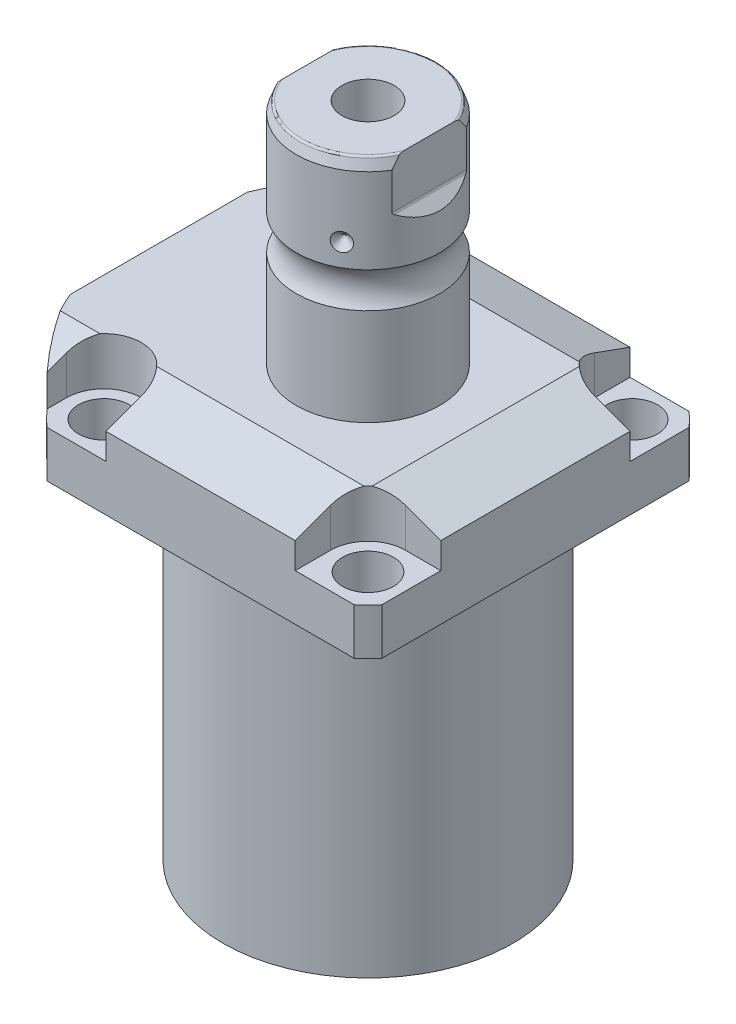
from build123d import *

# Parameters (mm, degrees)
SKETCH1_W               = 88.9
SKETCH1_H               = 100
EXTRUDE1_DEPTH          = 113.919
SKETCH2_OUTSIDE_W       = 137.146
SKETCH2_OUTSIDE_H       = 126.046
SKETCH2_OUTSIDE_R       = 60.325
CUT_EXTRUDE1_DEPTH      = 114.919
SKETCH3_W               = 38.1002
SKETCH3_H               = 88.9
FILLET1_R               = 0.381
CUT_EXTRUDE2_DEPTH      = 12.7
CUT_EXTRUDE9_START      = -56.55
CUT_EXTRUDE9_DEPTH      = 102
CUT_EXTRUDE7_DEPTH      = 45.45
CUT_EXTRUDE7_DEPTH_BACK = 45.45
SKETCH10_R              = 1.1811
SKETCH11_R              = 1.1811
LPATTERN1_COUNT         = 2
LPATTERN1_PITCH         = 25.9588
CUT_EXTRUDE8_DEPTH      = 53.34
SKETCH17_W              = 6.7435
SKETCH17_H              = 12.319
HOLE1_AT_2_COUNT        = 2
HOLE1_AT_2_PITCH        = 70.104
HOLE1_AT_3_COUNT        = 2
HOLE1_AT_3_PITCH        = 99.142027577
HOLE1_AT_4_COUNT        = 2
HOLE1_AT_4_PITCH        = 70.104
CHAMFER1_SIZE           = 0.635
FILLET2_R               = 0.635
CIRPATTERN1_COUNT       = 3


with BuildPart() as part:
    # Sketch1 → Extrude1 (new body)
    with BuildSketch(Plane.ZX):
        with Locations((0, -5.55)):
            Rectangle(SKETCH1_W, SKETCH1_H)
    extrude(amount=EXTRUDE1_DEPTH)

    # Sketch2 outside → Cut-Extrude1 (cut, through all)
    with BuildSketch(Plane.XZ):
        with Locations((-5.55, 0)):
            Rectangle(SKETCH2_OUTSIDE_W, SKETCH2_OUTSIDE_H)
        Circle(SKETCH2_OUTSIDE_R, mode=Mode.SUBTRACT)
    extrude(amount=-CUT_EXTRUDE1_DEPTH, mode=Mode.SUBTRACT)

    # Sketch3 → Cut-Revolve1 (revolve, cut)
    with BuildSketch(Plane(origin=(0, 0, 0), x_dir=(0, 0, 1), z_dir=(1, 0, 0))):
        with Locations((57.5436, -44.45)):
            Rectangle(SKETCH3_W, SKETCH3_H)
    revolve(axis=Axis((0, 93.345, 0), (0, -1, 0)), mode=Mode.SUBTRACT)

    # Fillet1
    fillet1_edges = [part.edges().sort_by_distance(p)[0] for p in [
        (0, 88.9, -38.4935),
    ]]
    fillet(fillet1_edges, radius=FILLET1_R)

    # Sketch4 → Cut-Extrude2 (cut)
    with BuildSketch(Plane(origin=(0, 113.919, 0), x_dir=(-1, 0, 0), z_dir=(0, 1, 0))):
        with BuildLine():
            Line((-25.121, -44.45), (-25.121, -35.052))
            ThreePointArc((-25.121, -35.052), (-28.029722556, -28.029722556), (-35.052, -25.121))
            Line((-35.052, -25.121), (-44.45, -25.121))
            Line((-44.45, -25.121), (-44.45, -44.45))
            Line((-44.45, -44.45), (-25.121, -44.45))
        make_face()
        with BuildLine():
            Line((44.983, -44.45), (25.121, -44.45))
            Line((25.121, -44.45), (25.121, -35.052))
            ThreePointArc((25.121, -35.052), (35.052, -25.121), (44.983, -35.052))
            Line((44.983, -35.052), (44.983, -44.45))
        make_face()
        with BuildLine():
            Line((25.121, 44.45), (25.121, 35.052))
            ThreePointArc((25.121, 35.052), (35.052, 25.121), (44.983, 35.052))
            Line((44.983, 35.052), (44.983, 44.45))
            Line((44.983, 44.45), (25.121, 44.45))
        make_face()
        with BuildLine():
            Line((-35.052, 25.121), (-44.45, 25.121))
            Line((-44.45, 25.121), (-44.45, 44.45))
            Line((-44.45, 44.45), (-25.121, 44.45))
            Line((-25.121, 44.45), (-25.121, 35.052))
            ThreePointArc((-25.121, 35.052), (-28.029722556, 28.029722556), (-35.052, 25.121))
        make_face()
    extrude(amount=-CUT_EXTRUDE2_DEPTH, mode=Mode.SUBTRACT)

    # Sketch5 → Cut-Extrude9 (cut)
    with BuildSketch(Plane(origin=(0, 0, 0), x_dir=(0, 0, -1), z_dir=(1, 0, 0)).offset(CUT_EXTRUDE9_START)):
        Polygon((-28.575, 113.919), (-44.45, 108.140972531), (-44.45, 113.919), align=None)
    cut_extrude9 = extrude(amount=CUT_EXTRUDE9_DEPTH, mode=Mode.SUBTRACT)

    # Mirror1: Cut-Extrude9 across plane
    add(cut_extrude9.mirror(Plane.XY), mode=Mode.SUBTRACT)

    # Sketch9 → Cut-Extrude7 (cut, two sides)
    with BuildSketch(Plane.XY) as cut_extrude7_sk:
        Polygon((28.575, 113.919), (44.45, 108.140972531), (44.45, 113.919), align=None)
    extrude(amount=CUT_EXTRUDE7_DEPTH, mode=Mode.SUBTRACT)
    extrude(cut_extrude7_sk.sketch, amount=-CUT_EXTRUDE7_DEPTH_BACK, mode=Mode.SUBTRACT)

    # Sketch20 → Cut-Revolve4 (revolve, cut)
    with BuildSketch(Plane(origin=(-41.402, 88.9, -18.1102), x_dir=(0, 1, 0), z_dir=(1, 0, 0)), mode=Mode.PRIVATE) as cut_revolve4_sk:
        Polygon((0, 41.9225), (1.4478, 41.9225), (1.4478, 39.4714), (2.4638, 39.4714), (2.4638, 37.4648), (13.4366, 37.4648), (13.4366, 36.2202), (0, 36.2202), align=None)
    cut_revolve4 = revolve(cut_revolve4_sk.sketch.rotate(Axis((-41.402, 81.620304954, 18.11), (0, 1, 0)), 180), axis=Axis((-41.402, 81.620304954, 18.11), (0, 1, 0)), mode=Mode.SUBTRACT)  # turned: the seam where the file's is

    # Mirror10: Cut-Revolve4 across plane
    add(cut_revolve4.mirror(Plane.XY), mode=Mode.SUBTRACT)

    # S2D0007 → Cut-Revolve2 (revolve, cut)
    with BuildSketch(Plane(origin=(-55.5498, 101.9048, 12.9794), x_dir=(0, 1, 0), z_dir=(0, 0, 1)), mode=Mode.PRIVATE) as cut_revolve2_sk:
        Polygon((0.0002, 0.0002), (10.7444, 0.0002), (10.7444, -0.2538), (6.655, -0.2538), (5.9438, -0.965), (5.9438, -14.427), (0.0002, -14.427), align=None)
    cut_revolve2 = revolve(cut_revolve2_sk.sketch.rotate(Axis((-40.6146, 101.905, 12.9794), (-1, 0, 0)), 90), axis=Axis((-40.6146, 101.905, 12.9794), (-1, 0, 0)), mode=Mode.SUBTRACT)  # turned: the seam where the file's is

    # LPattern1: Cut-Revolve2 ×2
    with Locations(*[(0, 0, -i * LPATTERN1_PITCH) for i in range(1, LPATTERN1_COUNT)]):
        add(cut_revolve2, mode=Mode.SUBTRACT)

    # Sketch15 → Revolve3 (revolve)
    with BuildSketch(Plane(origin=(0, 0, 0), x_dir=(0, -1, 0), z_dir=(1, 0, 0)), mode=Mode.PRIVATE) as revolve3_sk:
        with BuildLine():
            Line((-113.919, 0), (-113.919, 19.05))
            Line((-113.919, 19.05), (-139.640705156, 19.05))
            ThreePointArc((-139.640705156, 19.05), (-144.348, 17.5005), (-149.055294844, 19.05))
            Line((-149.055294844, 19.05), (-171.602, 19.05))
            Line((-171.602, 19.05), (-174.523, 17.986842946))
            Line((-174.523, 17.986842946), (-174.523, 0))
            Line((-174.523, 0), (-113.919, 0))
        make_face()
    revolve(revolve3_sk.sketch.rotate(Axis((0, 197.63613, 0), (0, -1, 0)), 180), axis=Axis((0, 197.63613, 0), (0, -1, 0)))  # turned: the seam where the file's is

    # Sketch16 → Cut-Extrude8 (cut, symmetric)
    with BuildSketch(Plane(origin=(0, 0, 0), x_dir=(0, -1, 0), z_dir=(0, 0, 1))):
        with BuildLine():
            Line((-174.523, 19.05), (-158.738369265, 19.05))
            Line((-158.738369265, 19.05), (-161.284184633, 16.504184633))
            ThreePointArc((-161.284184633, 16.504184633), (-161.531395225, 16.339003796), (-161.823, 16.281))
            Line((-161.823, 16.281), (-174.523, 16.281))
            Line((-174.523, 16.281), (-174.523, 19.05))
        make_face()
        with BuildLine():
            Line((-174.523, -19.05), (-174.523, -16.281))
            Line((-174.523, -16.281), (-161.823, -16.281))
            ThreePointArc((-161.823, -16.281), (-161.531395225, -16.339003796), (-161.284184633, -16.504184633))
            Line((-161.284184633, -16.504184633), (-158.738369265, -19.05))
            Line((-158.738369265, -19.05), (-174.523, -19.05))
        make_face()
    extrude(amount=CUT_EXTRUDE8_DEPTH, both=True, mode=Mode.SUBTRACT)

    # Sketch17 → Hole1 (revolve, cut)
    with BuildSketch(Plane(origin=(35.052, 101.219, -35.052), x_dir=(0, 0, 1), z_dir=(1, 0, 0))):
        with Locations((3.37175, 6.1595)):
            Rectangle(SKETCH17_W, SKETCH17_H)
    hole1 = revolve(axis=Axis((35.052, -8.781, -35.052), (0, 1, 0)), mode=Mode.SUBTRACT)

    # Hole1 at 2: Hole1 ×2
    with Locations(*[(0, 0, i * HOLE1_AT_2_PITCH) for i in range(1, HOLE1_AT_2_COUNT)]):
        add(hole1, mode=Mode.SUBTRACT)

    # Hole1 at 3: Hole1 ×2
    with Locations(*[Vector(-0.707106781, 0, 0.707106781) * (i * HOLE1_AT_3_PITCH) for i in range(1, HOLE1_AT_3_COUNT)]):
        add(hole1, mode=Mode.SUBTRACT)

    # Hole1 at 4: Hole1 ×2
    with Locations(*[(-i * HOLE1_AT_4_PITCH, 0, 0) for i in range(1, HOLE1_AT_4_COUNT)]):
        add(hole1, mode=Mode.SUBTRACT)

    # Chamfer1
    chamfer1_edges = [part.edges().sort_by_distance(p)[0] for p in [
        (-41.402, 91.3638, 19.3546),
        (-41.402, 91.3638, -19.3546),
    ]]
    chamfer(chamfer1_edges, length=CHAMFER1_SIZE)

    # Sketch21 → Cut-Revolve5 (revolve, cut)
    with BuildSketch(Plane.XY, mode=Mode.PRIVATE) as cut_revolve5_sk:
        Polygon((0, 144.956512296), (6.9342, 149.123), (6.9342, 174.523), (0, 174.523), align=None)
    revolve(cut_revolve5_sk.sketch.rotate(Axis((0, 0, 0), (0, 1, 0)), 270), axis=Axis((0, 0, 0), (0, 1, 0)), mode=Mode.SUBTRACT)  # turned: the seam where the file's is

    # Fillet2
    fillet2_edges = [part.edges().sort_by_distance(p)[0] for p in [
        (0, 174.523, -17.986842946),
        (0, 174.523, 17.986842946),
    ]]
    fillet(fillet2_edges, radius=FILLET2_R)

    # Sketch22 → Cut-Revolve6 (revolve, cut)
    with BuildSketch(Plane.XY, mode=Mode.PRIVATE) as cut_revolve6_sk:
        Polygon((-19.05, 157.429), (-16.637, 155.016), (-19.05, 155.016), align=None)
    cut_revolve6 = revolve(cut_revolve6_sk.sketch.rotate(Axis((-37.997376206, 155.016, 0), (1, 0, 0)), 90), axis=Axis((-37.997376206, 155.016, 0), (1, 0, 0)), mode=Mode.SUBTRACT)  # turned: the seam where the file's is

    # CirPattern1: Cut-Revolve6 ×3 about axis
    cirpattern1_axis = Axis((0, 197.63613, 0), (0, 1, 0))
    for i in range(1, CIRPATTERN1_COUNT):
        add(cut_revolve6.rotate(cirpattern1_axis, i * 360 / CIRPATTERN1_COUNT), mode=Mode.SUBTRACT)


with BuildPart() as body_2:
    # Sketch10 → Revolve4 (revolve)
    with BuildSketch(Plane(origin=(-41.402, 88.9, -18.1102), x_dir=(0, 1, 0), z_dir=(1, 0, 0))):
        with Locations((0.2667, 4.5214)):
            Circle(SKETCH10_R)
    revolve(axis=Axis((-41.402, 87.86749, -18.11), (0, 1, 0)))


with BuildPart() as body_3:
    # Sketch11 → Revolve2 (revolve)
    with BuildSketch(Plane(origin=(-41.402, 88.9, 18.1102), x_dir=(0, 1, 0), z_dir=(1, 0, 0)), mode=Mode.PRIVATE) as revolve2_sk:
        with Locations((0.2667, 4.521)):
            Circle(SKETCH11_R)
    revolve(revolve2_sk.sketch.rotate(Axis((-41.402, 87.86749, 18.11), (0, 1, 0)), 180), axis=Axis((-41.402, 87.86749, 18.11), (0, 1, 0)))  # turned: the seam where the file's is


solid = Compound([part.part, body_2.part, body_3.part])
